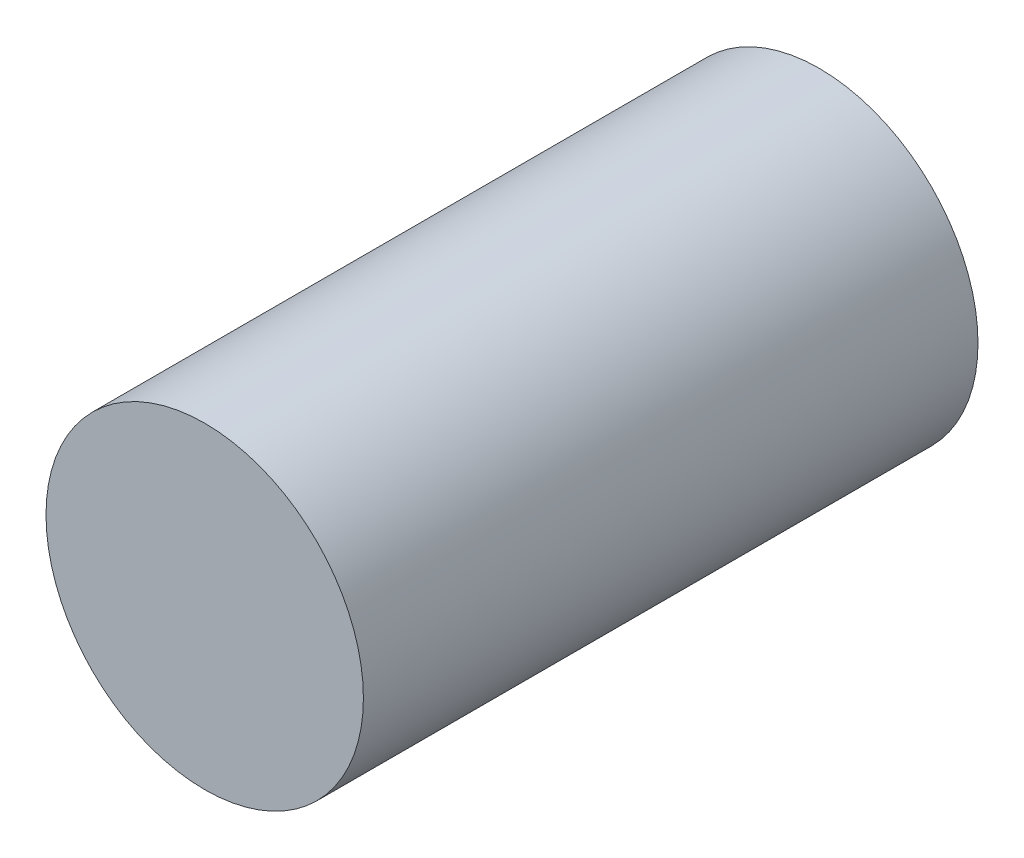
from build123d import *

# Parameters (mm, degrees)
SKETCH1_R           = 3.925
BOSS_EXTRUDE1_DEPTH = 15.2


with BuildPart() as part:
    # Sketch1 → Boss-Extrude1 (new body)
    with BuildSketch(Plane.XY):
        Circle(SKETCH1_R)
    extrude(amount=BOSS_EXTRUDE1_DEPTH)


solid = part.part
